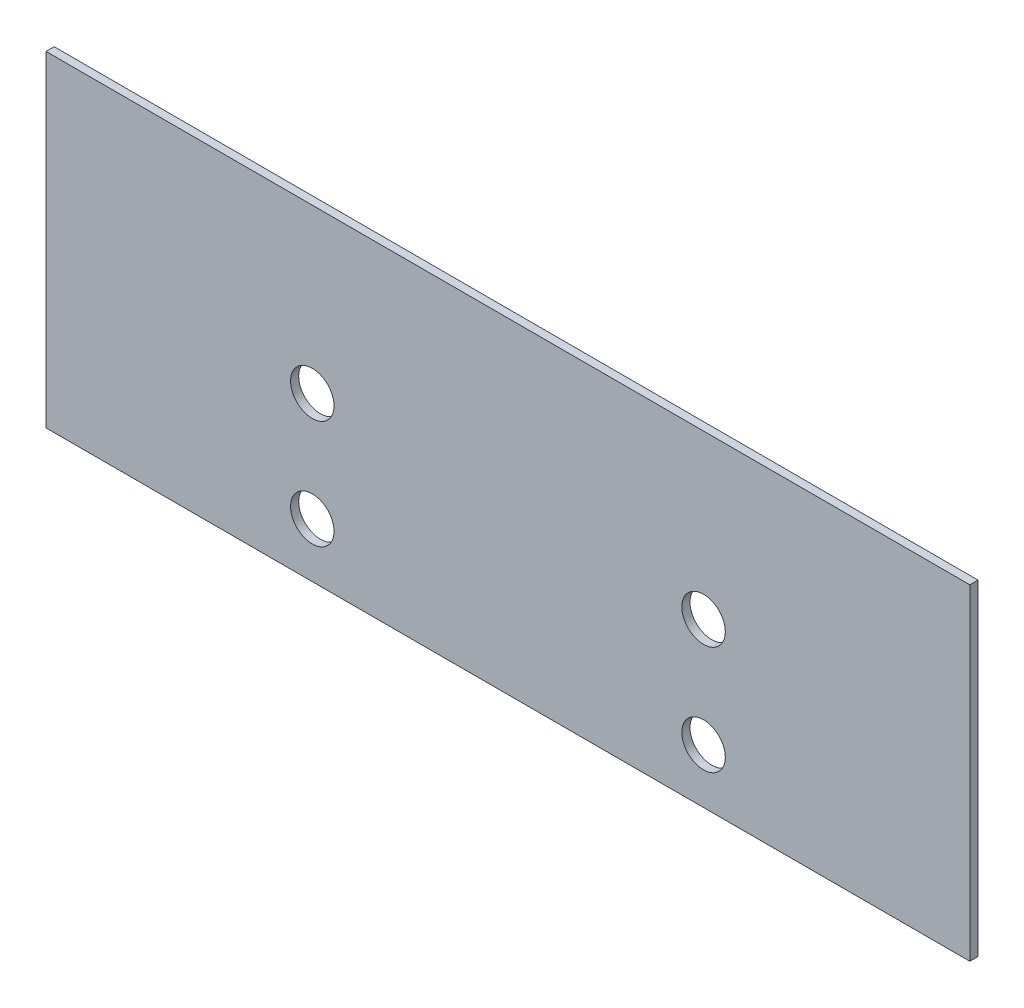
from build123d import *

# Parameters (mm, degrees)
CROQUIS1_W              = 170
CROQUIS1_H              = 60
SALIENTE_EXTRUIR1_DEPTH = 1.5
CROQUIS2_R              = 4
CORTAR_EXTRUIR1_DEPTH   = 1.5


with BuildPart() as part:
    # Croquis1 → Saliente-Extruir1 (new body)
    with BuildSketch(Plane.XY):
        Rectangle(CROQUIS1_W, CROQUIS1_H)
    extrude(amount=SALIENTE_EXTRUIR1_DEPTH)

    # Croquis2 → Cortar-Extruir1 (cut)
    with BuildSketch(Plane.XY.offset(1.5)):
        with Locations((-35.99999999, -20)):
            Circle(CROQUIS2_R)
        with Locations((-35.99999999, 0)):
            Circle(CROQUIS2_R)
        with Locations((36.00000001, -20)):
            Circle(CROQUIS2_R)
        with Locations((36.00000001, 0)):
            Circle(CROQUIS2_R)
    extrude(amount=-CORTAR_EXTRUIR1_DEPTH, mode=Mode.SUBTRACT)


solid = part.part
